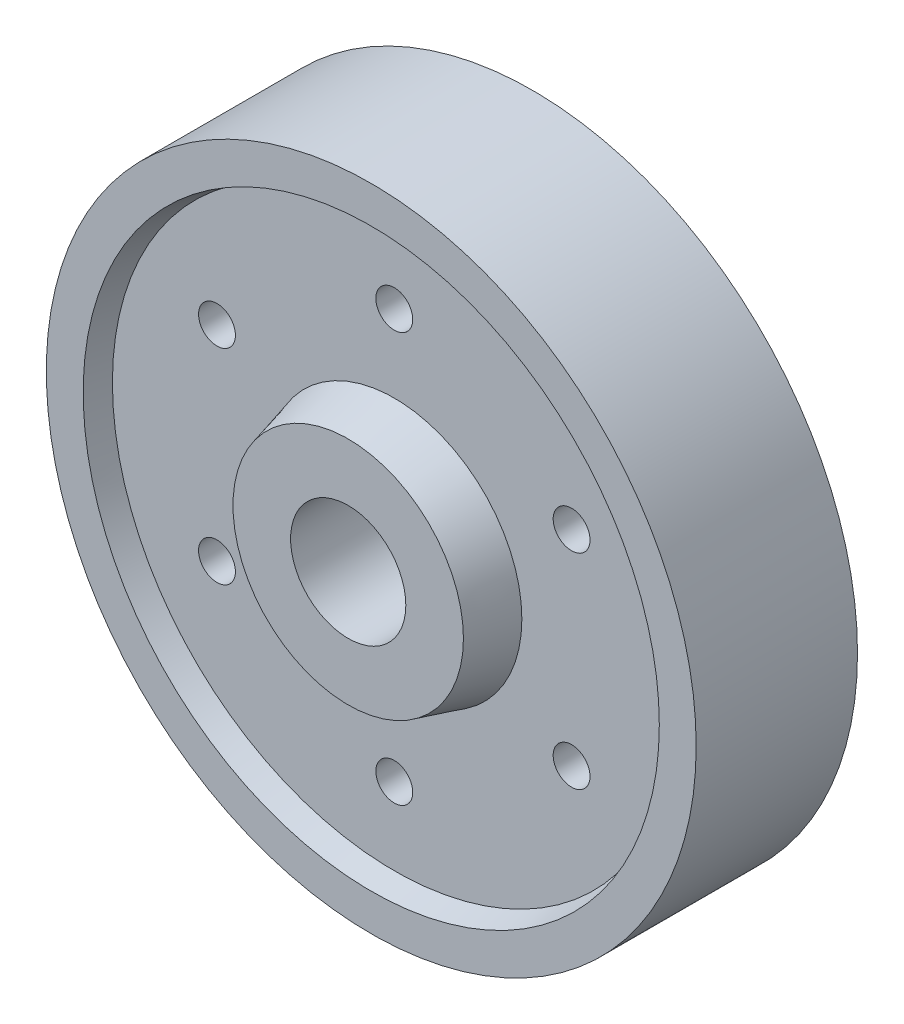
from build123d import *

# Parameters (mm, degrees)
CUT_EXTRUDE2_REACH = 37
SKETCH9_R          = 4


with BuildPart() as part:
    # Sketch8 → Revolve3 (revolve)
    with BuildSketch(Plane(origin=(0, 0, 0), x_dir=(0, 0, -1), z_dir=(1, 0, 0))):
        Polygon((22.5, 12.5), (-22.5, 12.5), (-22.5, 25), (-12.5, 27.679491924), (-12.5, 61.160254038), (-17.5, 62.5), (-17.5, 70.5), (17.5, 70.5), (17.5, 62.5), (12.5, 61.160254038), (12.5, 27.679491924), (22.5, 25), align=None)
    revolve(axis=Axis((0, 0, 62.265479925), (0, 0, -1)))

    # Sketch9 → Cut-Extrude2 (cut, up to next)
    with BuildSketch(Plane.XY.offset(12.5), mode=Mode.PRIVATE) as cut_extrude2_sk1:
        with Locations((0, 44.419872981)):
            Circle(SKETCH9_R)
    cut_extrude2_tool1 = extrude(cut_extrude2_sk1.sketch, amount=-CUT_EXTRUDE2_REACH, mode=Mode.PRIVATE) & part.part
    add(cut_extrude2_tool1.solids().sort_by_distance((0, 44.419873, 12.5))[0], mode=Mode.SUBTRACT)
    # Sketch9 → Cut-Extrude2 (cut, up to next)
    with BuildSketch(Plane.XY.offset(12.5), mode=Mode.PRIVATE) as cut_extrude2_sk2:
        with Locations((38.468738434, 22.209936491)):
            Circle(SKETCH9_R)
    cut_extrude2_tool2 = extrude(cut_extrude2_sk2.sketch, amount=-CUT_EXTRUDE2_REACH, mode=Mode.PRIVATE) & part.part
    add(cut_extrude2_tool2.solids().sort_by_distance((38.468738, 22.209936, 12.5))[0], mode=Mode.SUBTRACT)
    # Sketch9 → Cut-Extrude2 (cut, up to next)
    with BuildSketch(Plane.XY.offset(12.5), mode=Mode.PRIVATE) as cut_extrude2_sk3:
        with Locations((38.468738434, -22.209936491)):
            Circle(SKETCH9_R)
    cut_extrude2_tool3 = extrude(cut_extrude2_sk3.sketch, amount=-CUT_EXTRUDE2_REACH, mode=Mode.PRIVATE) & part.part
    add(cut_extrude2_tool3.solids().sort_by_distance((38.468738, -22.209936, 12.5))[0], mode=Mode.SUBTRACT)
    # Sketch9 → Cut-Extrude2 (cut, up to next)
    with BuildSketch(Plane.XY.offset(12.5), mode=Mode.PRIVATE) as cut_extrude2_sk4:
        with Locations((0, -44.419872981)):
            Circle(SKETCH9_R)
    cut_extrude2_tool4 = extrude(cut_extrude2_sk4.sketch, amount=-CUT_EXTRUDE2_REACH, mode=Mode.PRIVATE) & part.part
    add(cut_extrude2_tool4.solids().sort_by_distance((0, -44.419873, 12.5))[0], mode=Mode.SUBTRACT)
    # Sketch9 → Cut-Extrude2 (cut, up to next)
    with BuildSketch(Plane.XY.offset(12.5), mode=Mode.PRIVATE) as cut_extrude2_sk5:
        with Locations((-38.468738434, -22.209936491)):
            Circle(SKETCH9_R)
    cut_extrude2_tool5 = extrude(cut_extrude2_sk5.sketch, amount=-CUT_EXTRUDE2_REACH, mode=Mode.PRIVATE) & part.part
    add(cut_extrude2_tool5.solids().sort_by_distance((-38.468738, -22.209936, 12.5))[0], mode=Mode.SUBTRACT)
    # Sketch9 → Cut-Extrude2 (cut, up to next)
    with BuildSketch(Plane.XY.offset(12.5), mode=Mode.PRIVATE) as cut_extrude2_sk6:
        with Locations((-38.468738434, 22.209936491)):
            Circle(SKETCH9_R)
    cut_extrude2_tool6 = extrude(cut_extrude2_sk6.sketch, amount=-CUT_EXTRUDE2_REACH, mode=Mode.PRIVATE) & part.part
    add(cut_extrude2_tool6.solids().sort_by_distance((-38.468738, 22.209936, 12.5))[0], mode=Mode.SUBTRACT)


solid = part.part
